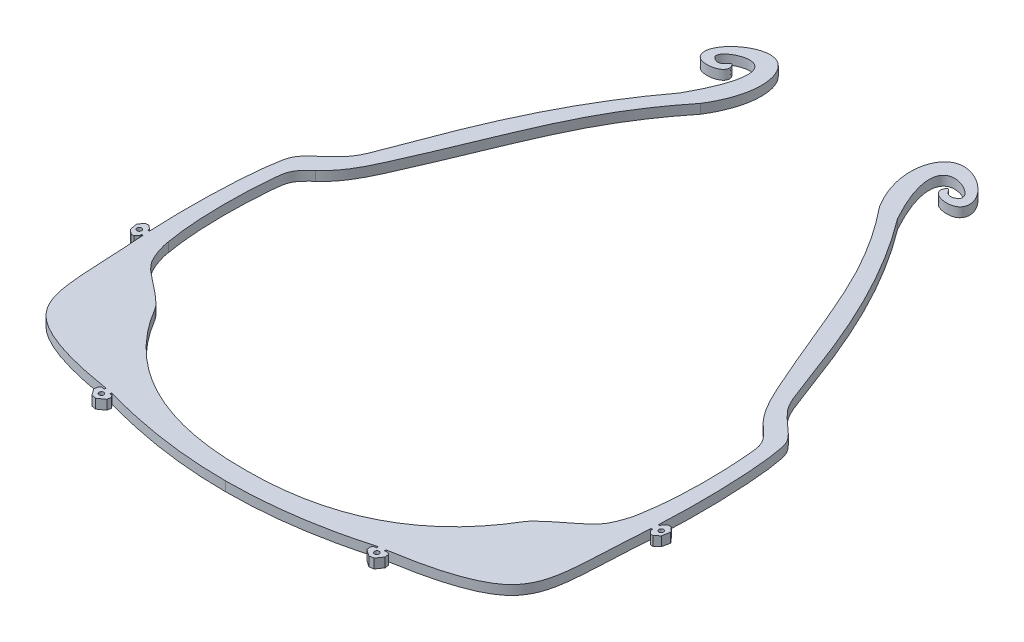
from build123d import *

# Parameters (mm, degrees)
SKETCH2_R           = 0.5
BOSS_EXTRUDE2_DEPTH = 2


with BuildPart() as part:
    # Sketch2 → Boss-Extrude2 (new body)
    with BuildSketch(Plane(origin=(0, 0, 0), x_dir=(1, 0, 0), z_dir=(0, 1, 0))):
        with BuildLine():
            Line((-94.784382596, 4647.050087279), (-93.820015858, 4645.684036588))
            Line((-93.820015858, 4645.684036588), (-92.856911312, 4645.510916044))
            Line((-92.856911312, 4645.510916044), (-91.478895982, 4646.483296749))
            Line((-91.478895982, 4646.483296749), (-91.338914474, 4647.291666779))
            Line((-91.338914474, 4647.291666779), (-91.65410664, 4647.738734517))
            Line((-91.65410664, 4647.738734517), (-92.214458731, 4647.8357386))
            Line((-92.214458731, 4647.8357386), (-92.123237704, 4648.181385636))
            Line((-92.123237704, 4648.181385636), (-92.120838895, 4648.190475))
            add(Edge.make_bspline(
                [(-63.949722772, 4644.102257444), (-78.035454467, 4644.104653229), (-92.120838895, 4648.190475)],
                knots=[0.500293183, 0.500293183, 0.500293183, 1, 1, 1], degree=2))
            add(Edge.make_bspline(
                [(-63.949722772, 4644.102257444), (-49.86399108, 4644.10465323), (-35.778606655, 4648.190475)],
                knots=[0.500293183, 0.500293183, 0.500293183, 1, 1, 1], degree=2))
            Line((-35.778606655, 4648.190475), (-35.776207847, 4648.181385636))
            Line((-35.776207847, 4648.181385636), (-35.684986819, 4647.8357386))
            Line((-35.684986819, 4647.8357386), (-36.245338911, 4647.738734517))
            Line((-36.245338911, 4647.738734517), (-36.560531076, 4647.291666779))
            Line((-36.560531076, 4647.291666779), (-36.420549568, 4646.483296749))
            Line((-36.420549568, 4646.483296749), (-35.042534238, 4645.510916044))
            Line((-35.042534238, 4645.510916044), (-34.079429692, 4645.684036588))
            Line((-34.079429692, 4645.684036588), (-33.115062954, 4647.050087279))
            Line((-33.115062954, 4647.050087279), (-33.260318937, 4647.888319705))
            Line((-33.260318937, 4647.888319705), (-33.684062669, 4648.187229077))
            Line((-33.684062669, 4648.187229077), (-34.299056655, 4648.0806454))
            Line((-34.299056655, 4648.0806454), (-34.327356819, 4648.4388362))
            add(Edge.make_bspline(
                [(-34.327356819, 4648.4388362), (-27.432708679, 4649.525607883), (-9.178271873, 4653.944624223), (-11.375228474, 4665.247096721), (-10.184962381, 4680.410552038)],
                knots=[0, 0, 0, 0, 0.392231671, 1, 1, 1, 1], degree=3))
            Line((-10.184962381, 4680.410552038), (-9.866416417, 4680.388911238))
            Line((-9.866416417, 4680.388911238), (-9.886736417, 4680.030263238))
            Line((-9.886736417, 4680.030263238), (-9.279127233, 4679.340959854))
            Line((-9.279127233, 4679.340959854), (-8.717257541, 4679.308820524))
            Line((-8.717257541, 4679.308820524), (-7.750826033, 4680.158344219))
            Line((-7.750826033, 4680.158344219), (-7.444630679, 4681.813024464))
            Line((-7.444630679, 4681.813024464), (-8.329007898, 4682.818938316))
            Line((-8.329007898, 4682.818938316), (-8.98520895, 4682.860958878))
            Line((-8.98520895, 4682.860958878), (-9.752040217, 4682.186037438))
            Line((-9.752040217, 4682.186037438), (-9.772131617, 4681.829370638))
            Line((-9.772131617, 4681.829370638), (-10.112978781, 4681.849944638))
            add(Edge.make_bspline(
                [(-10.112978781, 4681.849944638), (-9.507719106, 4693.31692401), (-10.390064259, 4707.982246776), (-12.56097781, 4712.366001506), (-17.577522287, 4715.756738722), (-22.709498004, 4728.464457626), (-28.540414523, 4746.838189372), (-40.949855543, 4763.347508549)],
                knots=[0, 0, 0, 0, 0.170777889, 0.204984692, 0.326836548, 0.407861227, 1, 1, 1, 1], degree=3))
            add(Edge.make_bspline(
                [(-40.949855543, 4763.347508549), (-44.366188632, 4769.525157954), (-46.69786763, 4780.444266937), (-35.866005096, 4774.697568249), (-40.221159081, 4772.13561066), (-40.800651092, 4774.930984711), (-42.591635076, 4771.681985009), (-37.099492426, 4770.571462955), (-34.341491521, 4775.706820673), (-47.00285379, 4785.518304153), (-49.702524015, 4771.115252899), (-45.009322001, 4763.578227206)],
                knots=[0, 0, 0, 0, 0.048334816, 0.142928243, 0.162159562, 0.231927069, 0.259382175, 0.409255519, 0.461523944, 0.763332252, 1, 1, 1, 1], degree=3))
            add(Edge.make_bspline(
                [(-16.569824995, 4710.549403876), (-19.596352753, 4713.085746678), (-31.015161527, 4737.824590848), (-33.883851992, 4749.693081034), (-45.009322001, 4763.578227206)],
                knots=[0, 0, 0, 0, 0.147117654, 0.925748444, 0.925748444, 0.925748444, 0.925748444], degree=3))
            add(Edge.make_bspline(
                [(-14.073916274, 4681.849944638), (-13.010040197, 4687.586042481), (-12.726457152, 4697.745608025), (-13.887769435, 4707.974519562), (-15.571518649, 4709.614807048), (-16.569824995, 4710.549403876)],
                knots=[0, 0, 0, 0, 0.797699661, 0.897699661, 1, 1, 1, 1], degree=3))
            add(Edge.make_bspline(
                [(-24.889174273, 4668.255204492), (-23.619270186, 4670.151900097), (-17.672375965, 4674.229828239), (-16.683305328, 4675.560080386), (-15.414797912, 4677.113559784), (-14.261208023, 4680.238580576), (-14.073916274, 4681.849944638)],
                knots=[0, 0, 0, 0, 0.517384858, 0.711983816, 0.762677817, 1, 1, 1, 1], degree=3))
            add(Edge.make_bspline(
                [(-63.949722775, 4648.190475), (-36.815551257, 4648.046726755), (-24.889174273, 4668.255204492)],
                knots=[0, 0, 0, 1, 1, 1], degree=2))
            add(Edge.make_bspline(
                [(-63.949722775, 4648.190475), (-91.083894294, 4648.046726755), (-103.010271277, 4668.255204492)],
                knots=[0, 0, 0, 1, 1, 1], degree=2))
            add(Edge.make_bspline(
                [(-103.010271277, 4668.255204492), (-104.280175364, 4670.151900097), (-110.227069585, 4674.229828239), (-111.216140222, 4675.560080386), (-112.484647638, 4677.113559784), (-113.638237527, 4680.238580576), (-113.825529276, 4681.849944638)],
                knots=[0, 0, 0, 0, 0.517384858, 0.711983816, 0.762677817, 1, 1, 1, 1], degree=3))
            add(Edge.make_bspline(
                [(-113.825529276, 4681.849944638), (-114.889405353, 4687.586042481), (-115.172988398, 4697.745608025), (-114.011676115, 4707.974519562), (-112.327926901, 4709.614807048), (-111.329620555, 4710.549403876)],
                knots=[0, 0, 0, 0, 0.797699661, 0.897699661, 1, 1, 1, 1], degree=3))
            add(Edge.make_bspline(
                [(-111.329620555, 4710.549403876), (-108.303092797, 4713.085746678), (-96.884284023, 4737.824590848), (-94.015593558, 4749.693081034), (-82.890123549, 4763.578227206)],
                knots=[0, 0, 0, 0, 0.147117654, 0.925748444, 0.925748444, 0.925748444, 0.925748444], degree=3))
            add(Edge.make_bspline(
                [(-86.949590007, 4763.347508549), (-83.533256918, 4769.525157954), (-81.20157792, 4780.444266937), (-92.033440454, 4774.697568249), (-87.67828647, 4772.13561066), (-87.098794459, 4774.930984711), (-85.307810474, 4771.681985009), (-90.799953124, 4770.571462955), (-93.55795403, 4775.706820673), (-80.896591761, 4785.518304153), (-78.196921535, 4771.115252899), (-82.890123549, 4763.578227206)],
                knots=[0, 0, 0, 0, 0.048334816, 0.142928243, 0.162159562, 0.231927069, 0.259382175, 0.409255519, 0.461523944, 0.763332252, 1, 1, 1, 1], degree=3))
            add(Edge.make_bspline(
                [(-117.786466769, 4681.849944638), (-118.391726444, 4693.31692401), (-117.509381292, 4707.982246776), (-115.338467741, 4712.366001506), (-110.321923263, 4715.756738722), (-105.189947546, 4728.464457626), (-99.359031027, 4746.838189372), (-86.949590007, 4763.347508549)],
                knots=[0, 0, 0, 0, 0.170777889, 0.204984692, 0.326836548, 0.407861227, 1, 1, 1, 1], degree=3))
            Line((-117.786466769, 4681.849944638), (-118.127313933, 4681.829370638))
            Line((-118.127313933, 4681.829370638), (-118.147405333, 4682.186037438))
            Line((-118.147405333, 4682.186037438), (-118.9142366, 4682.860958878))
            Line((-118.9142366, 4682.860958878), (-119.570437652, 4682.818938316))
            Line((-119.570437652, 4682.818938316), (-120.454814871, 4681.813024464))
            Line((-120.454814871, 4681.813024464), (-120.148619517, 4680.158344219))
            Line((-120.148619517, 4680.158344219), (-119.182188009, 4679.308820524))
            Line((-119.182188009, 4679.308820524), (-118.620318317, 4679.340959854))
            Line((-118.620318317, 4679.340959854), (-118.012709133, 4680.030263238))
            Line((-118.012709133, 4680.030263238), (-118.033029133, 4680.388911238))
            Line((-118.033029133, 4680.388911238), (-117.714483169, 4680.410552038))
            add(Edge.make_bspline(
                [(-93.572088731, 4648.4388362), (-100.466736871, 4649.525607883), (-118.721173677, 4653.944624223), (-116.524217076, 4665.247096721), (-117.714483169, 4680.410552038)],
                knots=[0, 0, 0, 0, 0.392231671, 1, 1, 1, 1], degree=3))
            Line((-93.572088731, 4648.4388362), (-93.600388895, 4648.0806454))
            Line((-93.600388895, 4648.0806454), (-94.215382881, 4648.187229077))
            Line((-94.215382881, 4648.187229077), (-94.639126613, 4647.888319705))
            Line((-94.639126613, 4647.888319705), (-94.784382596, 4647.050087279))
        make_face()
        with Locations((-93.095558694, 4646.968014081)):
            Circle(SKETCH2_R, mode=Mode.SUBTRACT)
        with Locations((-119.182188009, 4681.066950366)):
            Circle(SKETCH2_R, mode=Mode.SUBTRACT)
        with Locations((-34.803886856, 4646.968014081)):
            Circle(SKETCH2_R, mode=Mode.SUBTRACT)
        with Locations((-8.717257541, 4681.066950366)):
            Circle(SKETCH2_R, mode=Mode.SUBTRACT)
    extrude(amount=BOSS_EXTRUDE2_DEPTH)


solid = part.part
